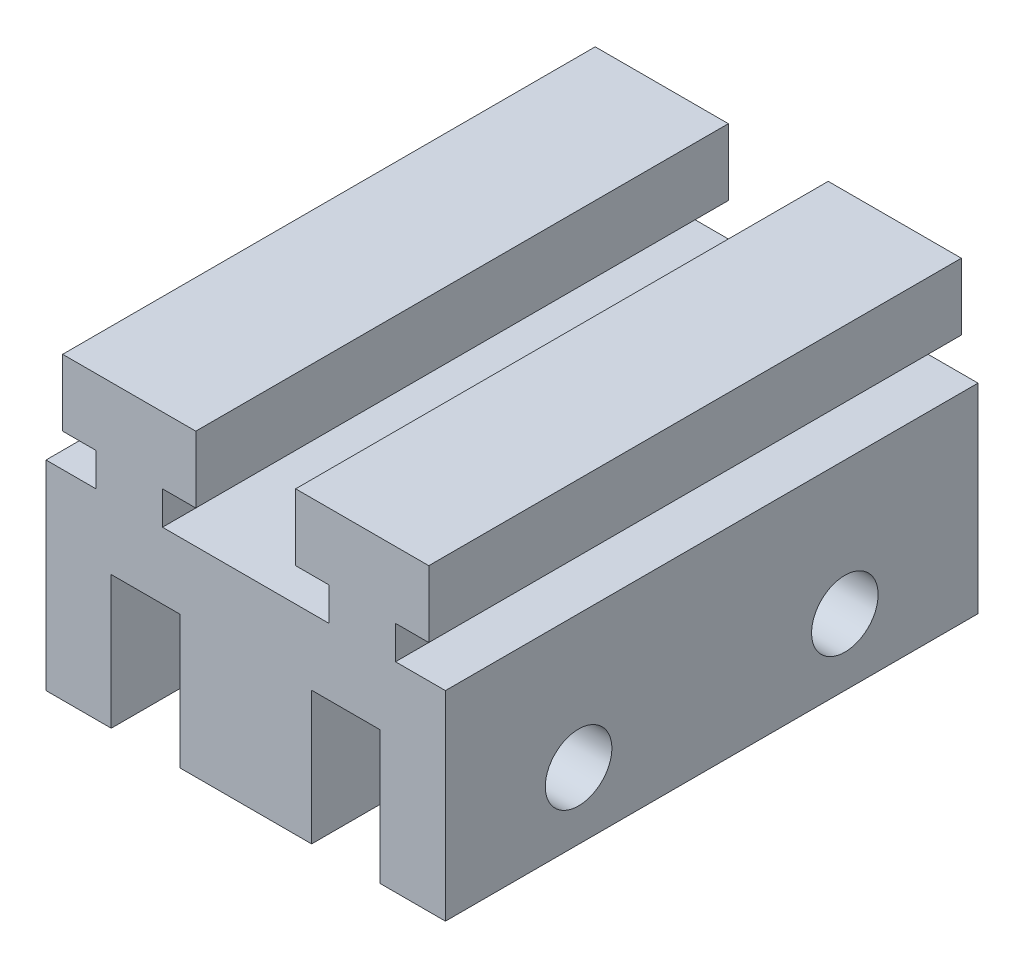
from build123d import *

# Parameters (mm, degrees)
SKETCH2_W             = 9.9
SKETCH2_H             = 40
BOSS_EXTRUDE1_DEPTH   = 10
SKETCH2_W_2           = 4.9
BOSS_EXTRUDE1_2_DEPTH = 10
BOSS_EXTRUDE1_3_DEPTH = 10
SKETCH3_R             = 2.5
CUT_EXTRUDE1_DEPTH    = 30
SKETCH4_W             = 30
SKETCH4_H             = 40
BOSS_EXTRUDE2_DEPTH   = 5
BOSS_EXTRUDE3_DEPTH   = 40


with BuildPart() as part:
    # Sketch2 → Boss-Extrude1 (new body)
    with BuildSketch(Plane(origin=(0, 0, 0), x_dir=(1, 0, 0), z_dir=(0, 1, 0))):
        Rectangle(SKETCH2_W, SKETCH2_H)
    extrude(amount=BOSS_EXTRUDE1_DEPTH)


with BuildPart() as body_2:
    # Sketch2 → Boss-Extrude1 2 (new body)
    with BuildSketch(Plane(origin=(0, 0, 0), x_dir=(1, 0, 0), z_dir=(0, 1, 0))):
        with Locations((-12.55, 0)):
            Rectangle(SKETCH2_W_2, SKETCH2_H)
    extrude(amount=BOSS_EXTRUDE1_2_DEPTH)


with BuildPart() as body_3:
    # Sketch2 → Boss-Extrude1 3 (new body)
    with BuildSketch(Plane(origin=(0, 0, 0), x_dir=(1, 0, 0), z_dir=(0, 1, 0))):
        with Locations((12.55, 0)):
            Rectangle(SKETCH2_W_2, SKETCH2_H)
    extrude(amount=BOSS_EXTRUDE1_3_DEPTH)


with BuildPart() as cut_extrude1_tool:
    # Sketch3 → Cut-Extrude1 (new body)
    with BuildSketch(Plane.ZY.offset(15)):
        with Locations((-10, 5)):
            Circle(SKETCH3_R)
        with Locations((10, 5)):
            Circle(SKETCH3_R)
    extrude(amount=-CUT_EXTRUDE1_DEPTH)


with BuildPart() as part_1:
    add(part.part)

    # Cut-Extrude1: cut by cut_extrude1_tool
    add(cut_extrude1_tool.part, mode=Mode.SUBTRACT)



with BuildPart() as body_2_1:
    add(body_2.part)

    # Cut-Extrude1: cut by cut_extrude1_tool
    add(cut_extrude1_tool.part, mode=Mode.SUBTRACT)


with BuildPart() as body_3_1:
    add(body_3.part)

    # Cut-Extrude1: cut by cut_extrude1_tool
    add(cut_extrude1_tool.part, mode=Mode.SUBTRACT)


with BuildPart() as part_2:
    add(part_1.part)

    add(body_2_1.part)  # Boss-Extrude2 merges body 2

    add(body_3_1.part)  # Boss-Extrude2 merges body 3
    # Sketch4 → Boss-Extrude2 (add)
    with BuildSketch(Plane(origin=(0, 10, 0), x_dir=(1, 0, 0), z_dir=(0, 1, 0))):
        Rectangle(SKETCH4_W, SKETCH4_H)
    extrude(amount=BOSS_EXTRUDE2_DEPTH)

    # Sketch5 → Boss-Extrude3 (add)
    with BuildSketch(Plane.XY.offset(20)):
        Polygon((-11.25, 15), (-11.25, 17.5), (-13.75, 17.5), (-13.75, 22.5), (-3.75, 22.5), (-3.75, 17.5), (-6.25, 17.5), (-6.25, 15), align=None)
    boss_extrude3 = extrude(amount=-BOSS_EXTRUDE3_DEPTH)

    # Mirror1: Boss-Extrude3 across Right Plane
    add(boss_extrude3.mirror(Plane(origin=(0, 0, 0), x_dir=(0, 0, -1), z_dir=(1, 0, 0))))


solid = part_2.part
